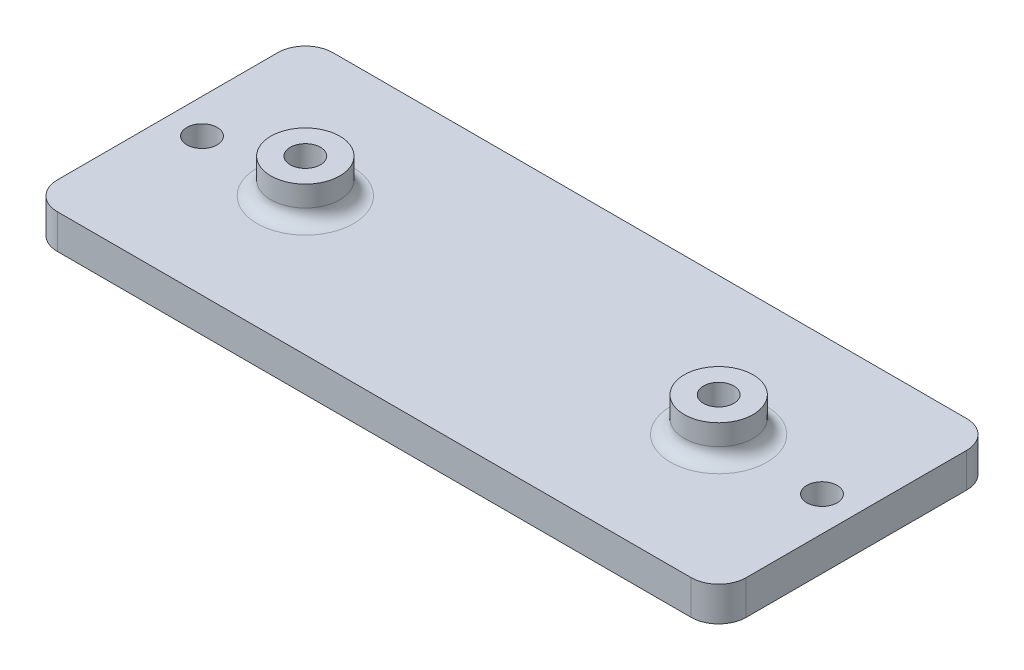
from build123d import *

# Parameters (mm, degrees)
BOSS_EXTRUDE1_DEPTH = 3.175
SKETCH2_R           = 3.175
BOSS_EXTRUDE2_DEPTH = 3.175
SKETCH3_R           = 1.397
CUT_EXTRUDE1_DEPTH  = 7.35
FILLET1_R           = 1.27
CUT_EXTRUDE2_REACH  = 5.175
SKETCH4_R           = 1.397


with BuildPart() as part:
    # Sketch1 → Boss-Extrude1 (new body)
    with BuildSketch(Plane(origin=(0, 0, 0), x_dir=(1, 0, 0), z_dir=(0, 1, 0))):
        with BuildLine():
            Line((-29.21, -12.7), (29.21, -12.7))
            ThreePointArc((29.21, -12.7), (31.006051224, -11.956051224), (31.75, -10.16))
            Line((31.75, -10.16), (31.75, 10.16))
            ThreePointArc((31.75, 10.16), (31.006051224, 11.956051224), (29.21, 12.7))
            Line((29.21, 12.7), (-29.21, 12.7))
            ThreePointArc((-29.21, 12.7), (-31.006051224, 11.956051224), (-31.75, 10.16))
            Line((-31.75, 10.16), (-31.75, -10.16))
            ThreePointArc((-31.75, -10.16), (-31.006051224, -11.956051224), (-29.21, -12.7))
        make_face()
    extrude(amount=BOSS_EXTRUDE1_DEPTH)

    # Sketch2 → Boss-Extrude2 (add)
    with BuildSketch(Plane(origin=(0, 3.175, 0), x_dir=(1, 0, 0), z_dir=(0, 1, 0))):
        with Locations((-19.05, 0)):
            Circle(SKETCH2_R)
        with Locations((19.05, 0)):
            Circle(SKETCH2_R)
    extrude(amount=BOSS_EXTRUDE2_DEPTH)

    # Sketch3 → Cut-Extrude1 (cut, through all)
    with BuildSketch(Plane(origin=(0, 6.35, 0), x_dir=(1, 0, 0), z_dir=(0, 1, 0))):
        with Locations((-19.05, 0)):
            Circle(SKETCH3_R)
        with Locations((19.05, 0)):
            Circle(SKETCH3_R)
    extrude(amount=-CUT_EXTRUDE1_DEPTH, mode=Mode.SUBTRACT)

    # Fillet1
    fillet1_edges = [part.edges().sort_by_distance(p)[0] for p in [
        (-22.225, 3.175, 0),
        (15.875, 3.175, 0),
    ]]
    fillet(fillet1_edges, radius=FILLET1_R)

    # Sketch4 → Cut-Extrude2 (cut, up to next)
    with BuildSketch(Plane(origin=(0, 3.175, 0), x_dir=(1, 0, 0), z_dir=(0, 1, 0)), mode=Mode.PRIVATE) as cut_extrude2_sk1:
        with Locations((-28.575, 0)):
            Circle(SKETCH4_R)
    cut_extrude2_tool1 = extrude(cut_extrude2_sk1.sketch, amount=-CUT_EXTRUDE2_REACH, mode=Mode.PRIVATE) & part.part
    add(cut_extrude2_tool1.solids().sort_by_distance((-28.575, 3.175, 0))[0], mode=Mode.SUBTRACT)
    # Sketch4 → Cut-Extrude2 (cut, up to next)
    with BuildSketch(Plane(origin=(0, 3.175, 0), x_dir=(1, 0, 0), z_dir=(0, 1, 0)), mode=Mode.PRIVATE) as cut_extrude2_sk2:
        with Locations((28.575, 0)):
            Circle(SKETCH4_R)
    cut_extrude2_tool2 = extrude(cut_extrude2_sk2.sketch, amount=-CUT_EXTRUDE2_REACH, mode=Mode.PRIVATE) & part.part
    add(cut_extrude2_tool2.solids().sort_by_distance((28.575, 3.175, 0))[0], mode=Mode.SUBTRACT)


solid = part.part
